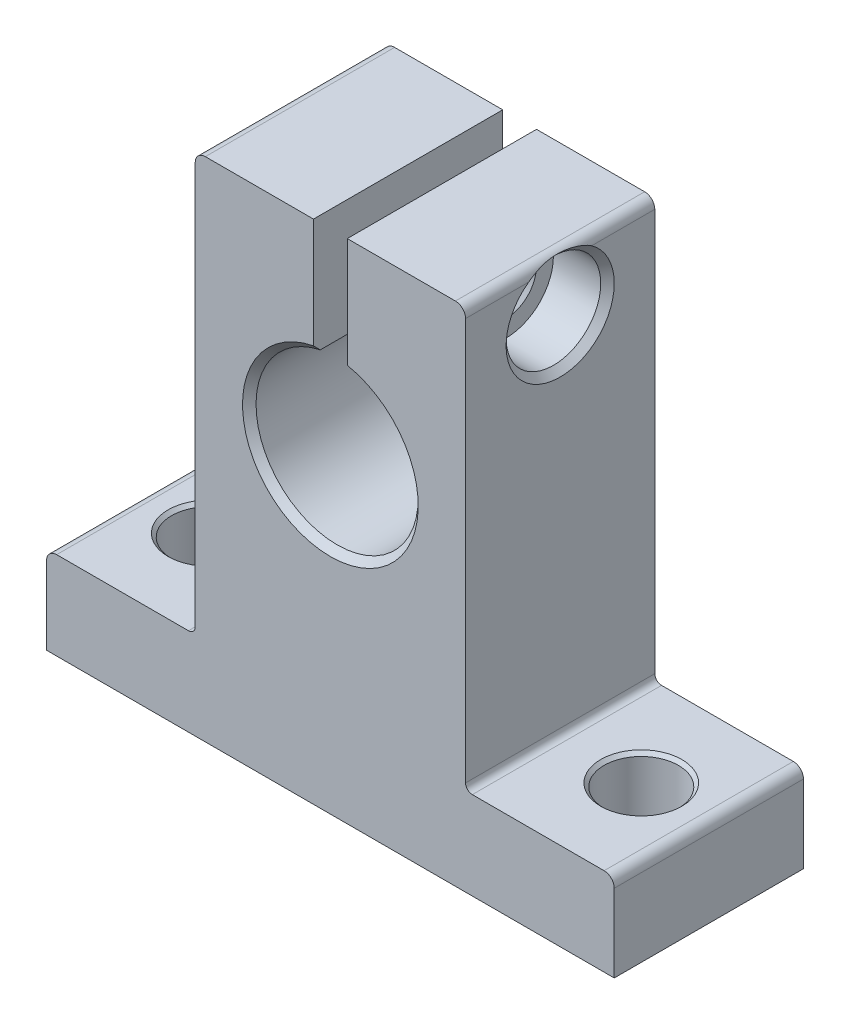
from build123d import *

# Parameters (mm, degrees)
BOSS_EXTRUDE1_DEPTH                 = 7
F_5_5_5_5_DIAMETER_HOLE2_AT_2_COUNT = 2
F_5_5_5_5_DIAMETER_HOLE2_AT_2_PITCH = 32
M3_5X0_6_TAPPED_HOLE1_D             = 2.9
M3_5X0_6_TAPPED_HOLE1_DEPTH         = 8.75
FILLET1_R                           = 0.75
FILLET1_2_R                         = 0.5
CHAMFER1_SIZE                       = 0.5


with BuildPart() as part:
    # Sketch2 → Boss-Extrude1 (new body, symmetric)
    with BuildSketch(Plane.XY):
        with BuildLine():
            Line((-21, -16.5), (-10, -16.5))
            Line((-10, -16.5), (-10, 14.5))
            Line((-10, 14.5), (-1.25, 14.5))
            Line((-1.25, 14.5), (-1.25, 5.868347297))
            ThreePointArc((-1.25, 5.868347297), (0, -6), (1.25, 5.868347297))
            Line((1.25, 5.868347297), (1.25, 14.5))
            Line((1.25, 14.5), (10, 14.5))
            Line((10, 14.5), (10, -16.5))
            Line((10, -16.5), (21, -16.5))
            Line((21, -16.5), (21, -23))
            Line((21, -23), (-21, -23))
            Line((-21, -23), (-21, -16.5))
        make_face()
    extrude(amount=BOSS_EXTRUDE1_DEPTH, both=True)

    # Sketch5 → 5.5 _5.5_ Diameter Hole2 (revolve, cut)
    with BuildSketch(Plane(origin=(-16, -16.5, 0), x_dir=(0, 0, 1), z_dir=(1, 0, 0))):
        Polygon((0, 0), (0, 6.5), (3, 6.5), (2.75, 6.25), (2.75, 0.25), (3, 0), align=None)
    f_5_5_5_5_diameter_hole2 = revolve(axis=Axis((-16, -10.15, 0), (0, -1, 0)), mode=Mode.SUBTRACT)

    # 5.5 _5.5_ Diameter Hole2 at 2: 5.5 _5.5_ Diameter Hole2 ×2
    with Locations(*[(i * F_5_5_5_5_DIAMETER_HOLE2_AT_2_PITCH, 0, 0) for i in range(1, F_5_5_5_5_DIAMETER_HOLE2_AT_2_COUNT)]):
        add(f_5_5_5_5_diameter_hole2, mode=Mode.SUBTRACT)

    # M3.5x0.6 Tapped Hole1
    with Locations(Plane.ZY.offset(10)):
        with Locations((0, 10.5)):
            Hole(M3_5X0_6_TAPPED_HOLE1_D / 2, depth=M3_5X0_6_TAPPED_HOLE1_DEPTH)

    # Fillet1
    fillet1_edges = [part.edges().sort_by_distance(p)[0] for p in [
        (10, 14.5, 0),
        (-10, 14.5, 0),
        (21, -16.5, 0),
        (-21, -16.5, 0),
    ]]
    fillet(fillet1_edges, radius=FILLET1_R)

    # Fillet1 2
    fillet1_2_edges = [part.edges().sort_by_distance(p)[0] for p in [
        (10, -16.5, 0),
        (-10, -16.5, 0),
    ]]
    fillet(fillet1_2_edges, radius=FILLET1_2_R)

    # Sketch12 → CBORE for M5 Hex Head Bolt1 (revolve, cut)
    with BuildSketch(Plane(origin=(10, 10.5, 0), x_dir=(0, 0, -1), z_dir=(0, 1, 0))):
        Polygon((0, 0), (0, 8.75), (2, 8.75), (2, 4.25), (2.25, 4), (3.5, 4), (3.5, 0.5), (4, 0), align=None)
    revolve(axis=Axis((16.35, 10.5, 0), (-1, 0, 0)), mode=Mode.SUBTRACT)

    # Chamfer1
    chamfer1_edges = [part.edges().sort_by_distance(p)[0] for p in [
        (0, -6, 7),
        (0, -6, -7),
    ]]
    chamfer(chamfer1_edges, length=CHAMFER1_SIZE)


solid = part.part
